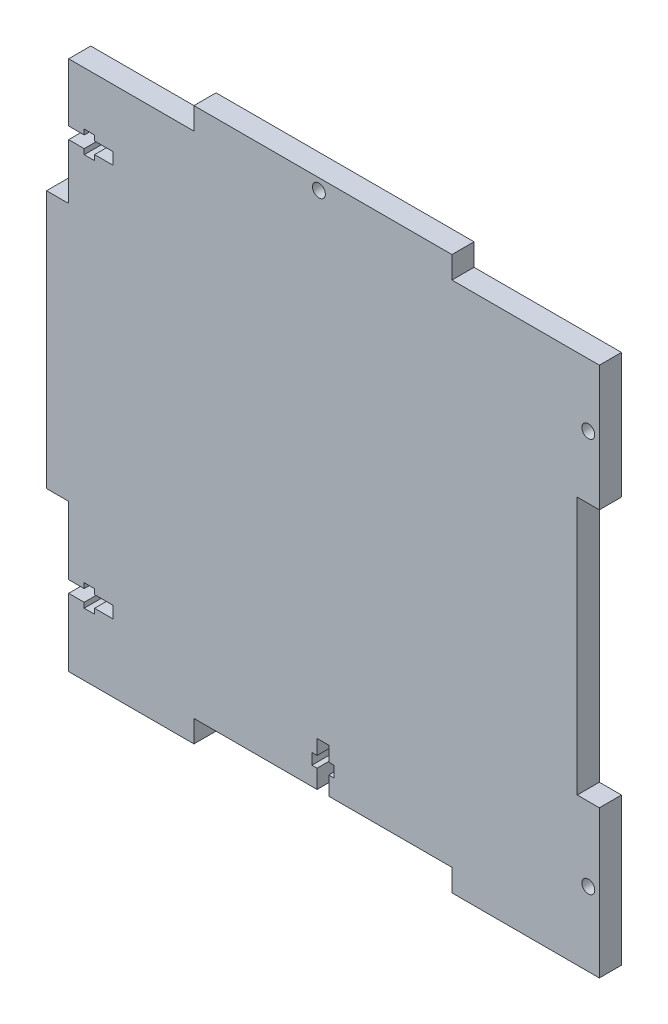
from build123d import *

# Parameters (mm, degrees)
SKETCH1_R           = 1.75
BOSS_EXTRUDE2_DEPTH = 6


with BuildPart() as part:
    # Sketch1 → Boss-Extrude2 (new body)
    with BuildSketch(Plane.XY):
        Polygon((72, 72), (32, 72), (32, 78), (-38, 78), (-38, 72), (-72, 72), (-72, 56.2), (-67.772810154, 56.2), (-67.772810154, 57.6), (-64.957983727, 57.6), (-64.957983727, 56.2), (-60, 56.2), (-60, 53), (-64.957983727, 53), (-64.957983727, 51.568504207), (-67.772810154, 51.568504207), (-67.772810154, 53), (-72, 53), (-72, 38), (-78, 38), (-78, -32), (-72, -32), (-72, -50.4), (-67.78187279, -50.4), (-67.78187279, -49), (-64.967046362, -49), (-64.967046362, -50.4), (-60, -50.4), (-60, -53.6), (-64.967046362, -53.6), (-64.967046362, -55), (-67.78187279, -55), (-67.78187279, -53.6), (-72, -53.6), (-72, -72), (-38, -72), (-38, -66), (-4.6, -66), (-4.6, -61), (-6, -61), (-6, -58), (-4.6, -58), (-4.6, -54), (-1.4, -54), (-1.4, -58), (0, -58), (0, -61), (-1.4, -61), (-1.4, -66), (32, -66), (32, -72), (72, -72), (72, -32), (66, -32), (66, 38), (72, 38), align=None)
        with Locations((69, -52)):
            Circle(SKETCH1_R, mode=Mode.SUBTRACT)
        with Locations((69, 55)):
            Circle(SKETCH1_R, mode=Mode.SUBTRACT)
        with Locations((-4.09, 75)):
            Circle(SKETCH1_R, mode=Mode.SUBTRACT)
    extrude(amount=BOSS_EXTRUDE2_DEPTH)


solid = part.part
